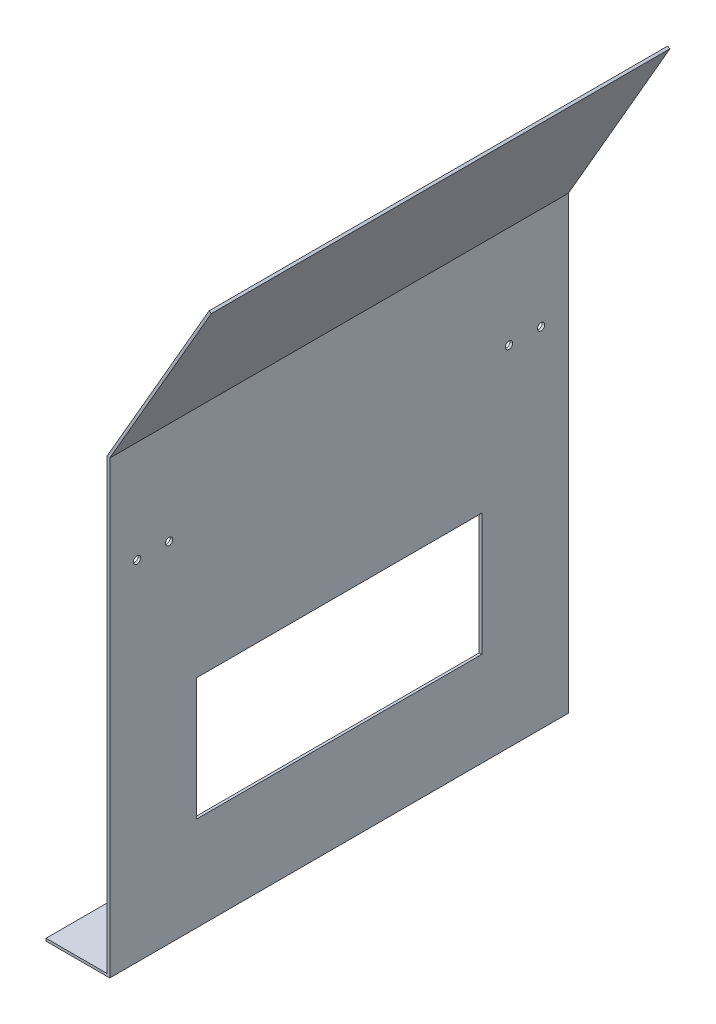
from build123d import *

# Parameters (mm, degrees)
BOSS_EXTRUDE1_DEPTH = 285.75
SKETCH2_W           = 177.8
SKETCH2_H           = 76.2
CUT_EXTRUDE1_DEPTH  = 40.7002
CUT_EXTRUDE2_REACH  = 41.7
SKETCH3_R           = 2.2479


with BuildPart() as part:
    # Sketch1 → Boss-Extrude1 (new body)
    with BuildSketch(Plane.XY):
        Polygon((0, 0), (0, 279.4), (63.5, 389.385226281), (64.885813851, 388.585126281), (1.6002, 278.971227702), (1.6002, 0), (1.6002, -1.6002), (0, -1.6002), (-38.1, -1.6002), (-38.1, 0), align=None)
    extrude(amount=BOSS_EXTRUDE1_DEPTH)

    # Sketch2 → Cut-Extrude1 (cut, through all)
    with BuildSketch(Plane(origin=(1.6002, 0, 0), x_dir=(0, 0, -1), z_dir=(1, 0, 0))):
        with Locations((-142.875, 95.25)):
            Rectangle(SKETCH2_W, SKETCH2_H)
    extrude(amount=-CUT_EXTRUDE1_DEPTH, mode=Mode.SUBTRACT)

    # Sketch3 → Cut-Extrude2 (cut, up to next)
    with BuildSketch(Plane(origin=(1.6002, 0, 0), x_dir=(0, 0, -1), z_dir=(1, 0, 0)), mode=Mode.PRIVATE) as cut_extrude2_sk1:
        with Locations((-268.762499939, 215.471227702)):
            Circle(SKETCH3_R)
    cut_extrude2_tool1 = extrude(cut_extrude2_sk1.sketch, amount=-CUT_EXTRUDE2_REACH, mode=Mode.PRIVATE) & part.part
    add(cut_extrude2_tool1.solids().sort_by_distance((1.6002, 215.471228, 268.7625))[0], mode=Mode.SUBTRACT)
    # Sketch3 → Cut-Extrude2 (cut, up to next)
    with BuildSketch(Plane(origin=(1.6002, 0, 0), x_dir=(0, 0, -1), z_dir=(1, 0, 0)), mode=Mode.PRIVATE) as cut_extrude2_sk2:
        with Locations((-248.762500061, 215.471227702)):
            Circle(SKETCH3_R)
    cut_extrude2_tool2 = extrude(cut_extrude2_sk2.sketch, amount=-CUT_EXTRUDE2_REACH, mode=Mode.PRIVATE) & part.part
    add(cut_extrude2_tool2.solids().sort_by_distance((1.6002, 215.471228, 248.7625))[0], mode=Mode.SUBTRACT)
    # Sketch3 → Cut-Extrude2 (cut, up to next)
    with BuildSketch(Plane(origin=(1.6002, 0, 0), x_dir=(0, 0, -1), z_dir=(1, 0, 0)), mode=Mode.PRIVATE) as cut_extrude2_sk3:
        with Locations((-16.987500061, 215.471227702)):
            Circle(SKETCH3_R)
    cut_extrude2_tool3 = extrude(cut_extrude2_sk3.sketch, amount=-CUT_EXTRUDE2_REACH, mode=Mode.PRIVATE) & part.part
    add(cut_extrude2_tool3.solids().sort_by_distance((1.6002, 215.471228, 16.9875))[0], mode=Mode.SUBTRACT)
    # Sketch3 → Cut-Extrude2 (cut, up to next)
    with BuildSketch(Plane(origin=(1.6002, 0, 0), x_dir=(0, 0, -1), z_dir=(1, 0, 0)), mode=Mode.PRIVATE) as cut_extrude2_sk4:
        with Locations((-36.987499939, 215.471227702)):
            Circle(SKETCH3_R)
    cut_extrude2_tool4 = extrude(cut_extrude2_sk4.sketch, amount=-CUT_EXTRUDE2_REACH, mode=Mode.PRIVATE) & part.part
    add(cut_extrude2_tool4.solids().sort_by_distance((1.6002, 215.471228, 36.9875))[0], mode=Mode.SUBTRACT)


solid = part.part
